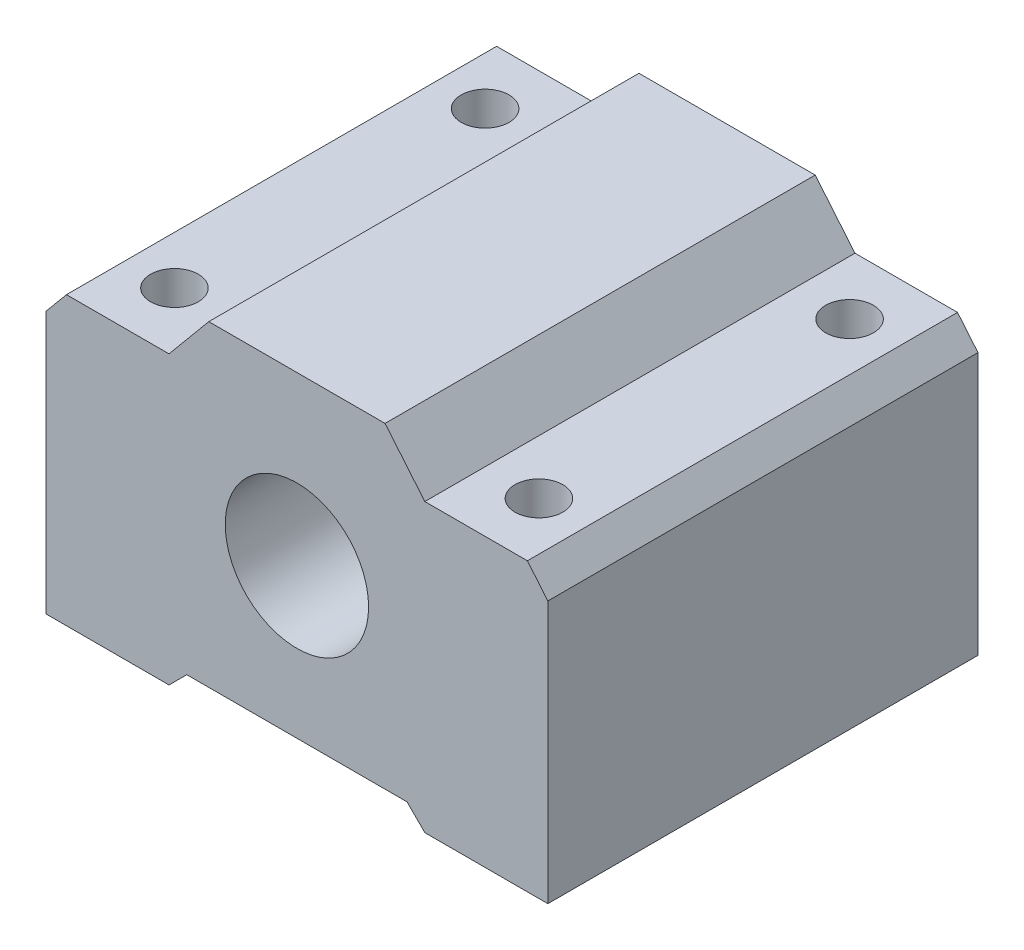
from build123d import *

# Parameters (mm, degrees)
SKETCH1_R           = 6
BOSS_EXTRUDE1_DEPTH = 36
CUT_EXTRUDE1_REACH  = 30
SKETCH2_R           = 2


with BuildPart() as part:
    # Sketch1 → Boss-Extrude1 (new body)
    with BuildSketch(Plane.XY):
        Polygon((-7.376347734, 14), (-10.704853009, 10), (-19.287228785, 10), (-21, 7.941693254), (-21, -14), (-12.193167268, -14), (-10.704853009, -14), (-9.216538749, -12.511685741), (9.216538749, -12.511685741), (10.704853009, -14), (12.193167268, -14), (21, -14), (21, 7.941693254), (19.287228785, 10), (10.704853009, 10), (7.376347734, 14), align=None)
        Circle(SKETCH1_R, mode=Mode.SUBTRACT)
    extrude(amount=BOSS_EXTRUDE1_DEPTH)

    # Sketch2 → Cut-Extrude1 (cut, up to next)
    with BuildSketch(Plane.XZ.offset(14), mode=Mode.PRIVATE) as cut_extrude1_sk1:
        with Locations((-15.25, 31)):
            Circle(SKETCH2_R)
    cut_extrude1_tool1 = extrude(cut_extrude1_sk1.sketch, amount=-CUT_EXTRUDE1_REACH, mode=Mode.PRIVATE) & part.part
    add(cut_extrude1_tool1.solids().sort_by_distance((-15.25, -14, 31))[0], mode=Mode.SUBTRACT)
    # Sketch2 → Cut-Extrude1 (cut, up to next)
    with BuildSketch(Plane.XZ.offset(14), mode=Mode.PRIVATE) as cut_extrude1_sk2:
        with Locations((15.25, 31)):
            Circle(SKETCH2_R)
    cut_extrude1_tool2 = extrude(cut_extrude1_sk2.sketch, amount=-CUT_EXTRUDE1_REACH, mode=Mode.PRIVATE) & part.part
    add(cut_extrude1_tool2.solids().sort_by_distance((15.25, -14, 31))[0], mode=Mode.SUBTRACT)
    # Sketch2 → Cut-Extrude1 (cut, up to next)
    with BuildSketch(Plane.XZ.offset(14), mode=Mode.PRIVATE) as cut_extrude1_sk3:
        with Locations((15.25, 5)):
            Circle(SKETCH2_R)
    cut_extrude1_tool3 = extrude(cut_extrude1_sk3.sketch, amount=-CUT_EXTRUDE1_REACH, mode=Mode.PRIVATE) & part.part
    add(cut_extrude1_tool3.solids().sort_by_distance((15.25, -14, 5))[0], mode=Mode.SUBTRACT)
    # Sketch2 → Cut-Extrude1 (cut, up to next)
    with BuildSketch(Plane.XZ.offset(14), mode=Mode.PRIVATE) as cut_extrude1_sk4:
        with Locations((-15.25, 5)):
            Circle(SKETCH2_R)
    cut_extrude1_tool4 = extrude(cut_extrude1_sk4.sketch, amount=-CUT_EXTRUDE1_REACH, mode=Mode.PRIVATE) & part.part
    add(cut_extrude1_tool4.solids().sort_by_distance((-15.25, -14, 5))[0], mode=Mode.SUBTRACT)


solid = part.part
